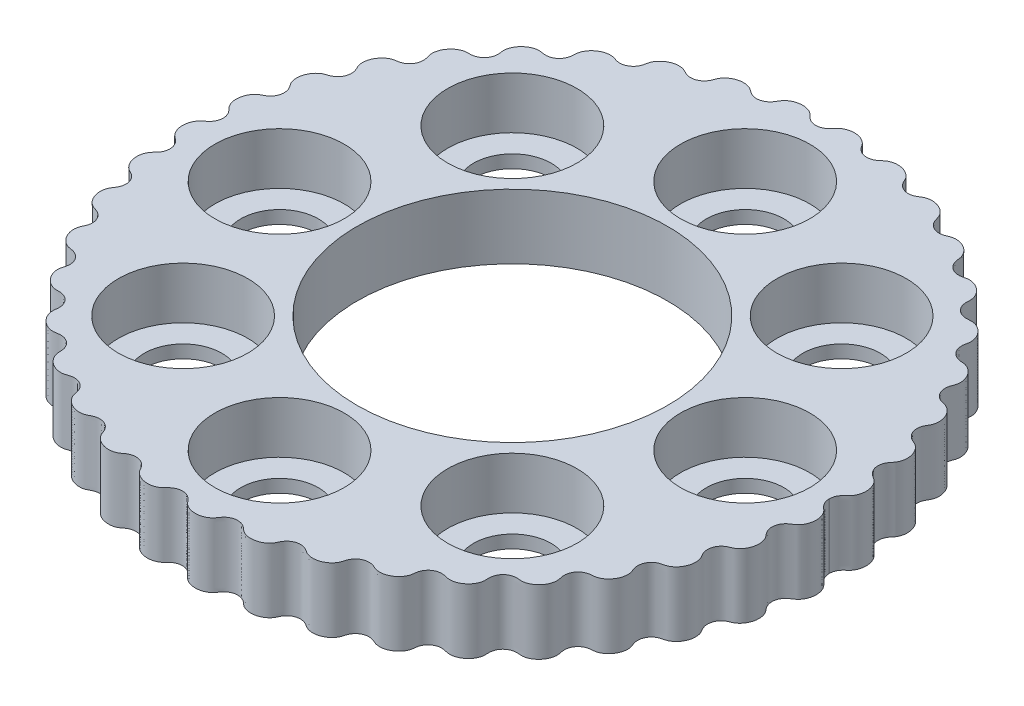
from build123d import *

# Parameters (mm, degrees)
BOSS_EXTRUDE1_DEPTH = 5
SKETCH2_R           = 12
CUT_EXTRUDE1_DEPTH  = 37.39383791
HOLE1_D             = 6
HOLE1_CBORE_D       = 10
HOLE1_CBORE_DEPTH   = 4


with BuildPart() as part:
    # Sketch1 → Boss-Extrude1 (new body)
    with BuildSketch(Plane(origin=(0, 0, 0), x_dir=(1, 0, 0), z_dir=(0, 1, 0))):
        with BuildLine():
            add(Edge.make_bspline(
                [(24.5, 0), (24.5, -0.032701576), (24.503643768, -0.098935065), (24.520100091, -0.231557515), (24.563306695, -0.37104905), (24.630474901, -0.517913129), (24.723536718, -0.659065523), (24.842442784, -0.7928284), (24.987483312, -0.908750967), (25.151066474, -1.063330899), (25.293016736, -1.285136586), (25.404935248, -1.590500326), (25.442358968, -1.973679703), (25.388238682, -2.341450403), (25.249908888, -2.662669139), (25.066237715, -2.92385167), (24.843285187, -3.097823526), (24.551710812, -3.251747242), (24.291807971, -3.54096186), (24.15685552, -3.887170811), (24.159964199, -4.245303416), (24.253524541, -4.539087991), (24.385168231, -4.771968939), (24.638807178, -5.019239878), (24.797525088, -5.397374474), (24.830645532, -5.836257731), (24.734992765, -6.249812375), (24.58195143, -6.558483237), (24.390234299, -6.791981719), (24.184935034, -6.970555692), (23.940854728, -7.065125184), (23.70713488, -7.165908686), (23.508700997, -7.31905902), (23.350412873, -7.502267838), (23.216949128, -7.764654988), (23.163202291, -8.07171217), (23.205655511, -8.393877158), (23.34132919, -8.675141439), (23.491049407, -8.894217402), (23.576162085, -9.177606247), (23.59831681, -9.499805745), (23.534839494, -9.847196253), (23.379813306, -10.190594913), (23.178906945, -10.450991493), (22.967567423, -10.630525296), (22.76488017, -10.742756992), (22.589184766, -10.797744014), (22.386815411, -10.837748424), (22.190086395, -10.90441667), (21.996608796, -11.016922348), (21.765137053, -11.234569902), (21.595631107, -11.53507583), (21.539371156, -11.906162162), (21.632077907, -12.284690713), (21.764581598, -12.549564385), (21.789593453, -12.787020837), (21.782131116, -13.023382407), (21.727181452, -13.289110072), (21.59506174, -13.600213655), (21.343195365, -13.928402366), (21.015174902, -14.168242881), (20.694719635, -14.280355125), (20.431319487, -14.282746618), (20.221891409, -14.310542511), (20.031331573, -14.365707475), (19.783881331, -14.493589444), (19.520218372, -14.750869647), (19.369080078, -15.105193456), (19.358026889, -15.501401935), (19.462600465, -15.83346109), (19.464472547, -16.137599181), (19.37969254, -16.467079723), (19.204137399, -16.797533997), (18.949742977, -17.076011566), (18.638873742, -17.274855126), (18.321682815, -17.389270021), (18.023392039, -17.405995877), (17.688466473, -17.348112955), (17.287573913, -17.422084381), (16.911103922, -17.660362817), (16.700986893, -18.014992072), (16.640562093, -18.330352665), (16.644508053, -18.592116874), (16.666618816, -18.82601978), (16.606844203, -19.103025495), (16.448349531, -19.431276831), (16.176752733, -19.744917149), (15.826597454, -19.975949924), (15.461825511, -20.085392014), (15.163898314, -20.094151912), (14.952002423, -20.049830261), (14.788464306, -20.001991568), (14.620523725, -19.975251306), (14.45147131, -19.973404939), (14.183542584, -20.011245044), (13.906637744, -20.136429959), (13.663310346, -20.365573728), (13.518257574, -20.658305683), (13.463367162, -20.873569048), (13.445828874, -21.065140231), (13.425857061, -21.227322141), (13.366593985, -21.41847997), (13.257220751, -21.627294), (13.067172231, -21.864497221), (12.773861495, -22.093697123), (12.447891767, -22.238196814), (12.113896771, -22.296901293), (11.843875828, -22.283192938), (11.645465808, -22.233946607), (11.478617258, -22.156632084), (11.326566352, -22.091661043), (11.144171978, -22.042843566), (10.93280916, -22.022823141), (10.645185326, -22.057480979), (10.363136796, -22.186462408), (10.140796211, -22.389999892), (9.978092899, -22.655161286), (9.908251546, -22.87392518), (9.860799925, -23.078666197), (9.75249434, -23.294506554), (9.598536155, -23.496595438), (9.355144691, -23.704201974), (9.012124782, -23.875609573), (8.668664808, -23.95138897), (8.351201234, -23.946909882), (8.105808961, -23.889981012), (7.933631196, -23.815733873), (7.793147129, -23.723462446), (7.667924569, -23.641344236), (7.516461261, -23.566205562), (7.337194915, -23.508022206), (7.051498599, -23.471278457), (6.693066572, -23.537697113), (6.365459458, -23.748903989), (6.158387947, -24.048645001), (6.064280146, -24.292320291), (5.942663508, -24.494976469), (5.777090182, -24.672238149), (5.520247205, -24.85479003), (5.157666726, -24.994457926), (4.786540614, -25.037338845), (4.432716206, -24.988008594), (4.169505623, -24.884468622), (3.995068344, -24.76880541), (3.865593686, -24.64527273), (3.75246931, -24.546581843), (3.609348309, -24.448937311), (3.431420351, -24.36469604), (3.162117249, -24.297268542), (2.858943617, -24.313903225), (2.575335551, -24.420915597), (2.355767483, -24.59000056), (2.224626458, -24.736967098), (2.127382836, -24.881995375), (2.043045477, -25.009111373), (1.905164792, -25.158865975), (1.698793095, -25.308147239), (1.397681156, -25.439850125), (1.001127424, -25.502965238), (0.629360335, -25.465313763), (0.307665383, -25.346652272), (0.083554098, -25.19865266), (-0.053247669, -25.060384865), (-0.177849686, -24.892575478), (-0.322474899, -24.735152133), (-0.518785328, -24.595698957), (-0.766051172, -24.499605568), (-1.014597734, -24.467450024), (-1.263114194, -24.492889318), (-1.493381339, -24.576146047), (-1.712279009, -24.70975626), (-1.890397157, -24.901293679), (-2.07636994, -25.098671273), (-2.32866393, -25.22802569), (-2.632218006, -25.321000895), (-2.995349195, -25.34150683), (-3.391344602, -25.269405683), (-3.725708861, -25.099770463), (-3.950250651, -24.900993941), (-4.079020729, -24.714342503), (-4.149949565, -24.578033667), (-4.268658176, -24.384436824), (-4.484903431, -24.155114304), (-4.801886029, -23.992662617), (-5.18889878, -23.961589677), (-5.490584047, -24.041418887), (-5.694287921, -24.146931761), (-5.850720051, -24.266746839), (-5.981065814, -24.369719852), (-6.16040384, -24.467085743), (-6.390667633, -24.539033606), (-6.697487103, -24.571284548), (-7.070614148, -24.521629541), (-7.403348707, -24.388735134), (-7.679033172, -24.191057274), (-7.858081579, -23.988606269), (-7.962893041, -23.812724578), (-8.023941839, -23.638949697), (-8.081282296, -23.483450327), (-8.170475424, -23.317503881), (-8.299773492, -23.150624497), (-8.519647903, -22.965662536), (-8.804465638, -22.847481657), (-9.105365522, -22.822461261), (-9.411188115, -22.884555638), (-9.621120987, -22.983491909), (-9.801541329, -23.093233424), (-10.031431095, -23.167757994), (-10.283339155, -23.19913264), (-10.602501211, -23.170425084), (-10.963787103, -23.044588325), (-11.259514034, -22.852072085), (-11.476293472, -22.621632625), (-11.630063579, -22.374885002), (-11.708363863, -22.123831658), (-11.736343148, -21.861885396), (-11.844524314, -21.61783222), (-12.032186567, -21.35340592), (-12.328822609, -21.137070451), (-12.705385685, -21.04295641), (-13.066996729, -21.097160696), (-13.307409925, -21.196997793), (-13.536665508, -21.252944303), (-13.77837002, -21.258651481), (-14.086089217, -21.203595324), (-14.431964506, -21.045493598), (-14.721938037, -20.816198333), (-14.930817787, -20.535754134), (-15.065261018, -20.246125075), (-15.10442204, -19.966040465), (-15.091955143, -19.636584148), (-15.21243879, -19.266876702), (-15.444788891, -18.976893756), (-15.756476898, -18.800505647), (-16.057689237, -18.734631805), (-16.325183333, -18.732180078), (-16.66614191, -18.828207236), (-17.072976965, -18.776617811), (-17.469630111, -18.585866473), (-17.779960001, -18.296264193), (-17.970766089, -18.009395581), (-18.077132086, -17.726619757), (-18.129143592, -17.459541596), (-18.089017162, -17.200873352), (-18.059424342, -16.948069783), (-18.092832029, -16.699643303), (-18.172342041, -16.470956712), (-18.33282806, -16.224182803), (-18.571854469, -16.024097936), (-18.872076179, -15.89976478), (-19.183499821, -15.876607617), (-19.448092275, -15.896740831), (-19.736076884, -15.828769667), (-20.026191899, -15.686865182), (-20.295309156, -15.458206374), (-20.515197271, -15.152256349), (-20.640263667, -14.848072234), (-20.690084273, -14.575281258), (-20.685945413, -14.343634561), (-20.645728369, -14.163984974), (-20.579189997, -13.968731532), (-20.538550902, -13.765032935), (-20.539232213, -13.541223669), (-20.611966932, -13.231930197), (-20.787450797, -12.934860229), (-21.080687212, -12.700582672), (-21.454854635, -12.591586732), (-21.750490597, -12.573906381), (-21.968640165, -12.476853202), (-22.169606876, -12.352216696), (-22.372265422, -12.171772927), (-22.575637161, -11.901807523), (-22.733936024, -11.519595952), (-22.777646195, -11.115603164), (-22.714525969, -10.782022834), (-22.584907631, -10.55270908), (-22.504249042, -10.357454899), (-22.456753436, -10.164837452), (-22.443729303, -9.886632044), (-22.53474337, -9.529600964), (-22.765917454, -9.221603427), (-23.103644674, -9.013804048), (-23.443302736, -8.938486015), (-23.707993378, -8.787795021), (-23.950263879, -8.550142078), (-24.150007487, -8.231911552), (-24.261724149, -7.874028108), (-24.28186652, -7.502915611), (-24.224809823, -7.211523469), (-24.139392481, -7.004744462), (-24.011104239, -6.822269336), (-23.857646612, -6.606828934), (-23.729838266, -6.261894418), (-23.751281283, -5.814263996), (-23.951133676, -5.456586741), (-24.195158438, -5.245732176), (-24.423265351, -5.118668975), (-24.637193052, -5.020649154), (-24.847031957, -4.830520586), (-25.052168709, -4.529069833), (-25.187932756, -4.137109743), (-25.21300136, -3.718333183), (-25.125395894, -3.347743415), (-24.984061866, -3.085338615), (-24.8397622, -2.923975617), (-24.716507014, -2.806333623), (-24.582959911, -2.641350087), (-24.435425812, -2.363628655), (-24.381922694, -2.017749962), (-24.468738378, -1.65011605), (-24.649609453, -1.378154585), (-24.808636544, -1.222902747), (-24.965741316, -1.111943364), (-25.096247421, -1.013546718), (-25.232180718, -0.866657289), (-25.358361578, -0.667519589), (-25.468779713, -0.384324223), (-25.52063487, -0.015695004), (-25.482799073, 0.33885919), (-25.366652837, 0.657464653), (-25.219778482, 0.884459828), (-25.077933053, 1.031673651), (-24.927554276, 1.137514944), (-24.795258705, 1.236705504), (-24.661779407, 1.370248952), (-24.538753327, 1.543277408), (-24.424946331, 1.809683005), (-24.395606024, 2.118427578), (-24.460685223, 2.412754489), (-24.608956423, 2.686249806), (-24.763487188, 2.856131444), (-24.917080186, 2.999593648), (-25.049860196, 3.201302698), (-25.147903631, 3.435675684), (-25.206010822, 3.750259895), (-25.182955693, 4.13302861), (-25.076862764, 4.468366321), (-24.914260914, 4.741064338), (-24.742269627, 4.925121879), (-24.591886352, 5.037116502), (-24.441737465, 5.112647655), (-24.308008591, 5.180030868), (-24.167201935, 5.273626227), (-24.027175363, 5.399777354), (-23.852494503, 5.628818781), (-23.730781573, 5.972437924), (-23.749874005, 6.361759002), (-23.905908751, 6.690967374), (-24.069879882, 6.894304953), (-24.184586702, 7.100946815), (-24.255321137, 7.332965409), (-24.285005422, 7.646671642), (-24.224682662, 8.030512168), (-24.076266111, 8.373361154), (-23.856641931, 8.655124788), (-23.635374032, 8.831310188), (-23.4479903, 8.924556929), (-23.276267219, 8.974922807), (-23.134229945, 9.023544143), (-22.978107304, 9.098662598), (-22.816193856, 9.210620378), (-22.623144868, 9.410113172), (-22.485950659, 9.680969632), (-22.436801923, 9.980084626), (-22.473435619, 10.254787868), (-22.535133786, 10.441849655), (-22.612107, 10.598584042), (-22.68002941, 10.735179433), (-22.740790781, 10.92946286), (-22.766895917, 11.182826715), (-22.730409086, 11.509450177), (-22.586802924, 11.884437908), (-22.368321683, 12.187578437), (-22.104717627, 12.406852922), (-21.864496168, 12.526947954), (-21.676356137, 12.576297871), (-21.468731485, 12.600303424), (-21.260084052, 12.646829229), (-21.041148953, 12.747104702), (-20.834288709, 12.91318749), (-20.682161616, 13.112348775), (-20.579924676, 13.340281597), (-20.536879444, 13.581322021), (-20.543127831, 13.837701107), (-20.61993552, 14.087734481), (-20.697897488, 14.347478781), (-20.683785544, 14.630648111), (-20.612539798, 14.940016064), (-20.448751, 15.264743617), (-20.188340372, 15.571630931), (-19.874283356, 15.776390385), (-19.58989404, 15.871482442), (-19.363878668, 15.889707198), (-19.210373958, 15.882982764), (-18.983382566, 15.888963171), (-18.676671333, 15.96152067), (-18.377464779, 16.154744755), (-18.156980749, 16.474328488), (-18.075213086, 16.775518432), (-18.064704915, 17.004712456), (-18.090236138, 17.200114585), (-18.114255608, 17.36449287), (-18.108933176, 17.568502975), (-18.05612259, 17.803915635), (-17.930651687, 18.085776991), (-17.701086983, 18.384107508), (-17.419631567, 18.605829308), (-17.110599699, 18.745750942), (-16.845749829, 18.799595156), (-16.641024702, 18.802435031), (-16.4600043, 18.768421661), (-16.296666195, 18.740325413), (-16.108358519, 18.734588876), (-15.899193762, 18.763114982), (-15.629078352, 18.861033231), (-15.384315321, 19.048581969), (-15.212178088, 19.296648508), (-15.113024415, 19.592546119), (-15.093725111, 19.823828708), (-15.098560094, 20.034951984), (-15.048167216, 20.271307357), (-14.949392422, 20.505157651), (-14.764959019, 20.767212125), (-14.475345402, 21.01718574), (-14.160763397, 21.17704356), (-13.852808891, 21.249571547), (-13.562235167, 21.259376051), (-13.305661875, 21.201675545), (-13.06482084, 21.094926302), (-12.799373568, 21.066575419), (-12.476542263, 21.096870033), (-12.140863779, 21.245583359), (-11.871067, 21.524628417), (-11.737189182, 21.864887905), (-11.703439736, 22.123010606), (-11.637276199, 22.349525559), (-11.521374322, 22.561705269), (-11.31984408, 22.800676005), (-11.009992109, 23.021172204), (-10.666434991, 23.157658443), (-10.319123465, 23.198344101), (-10.001074181, 23.169970457), (-9.738921246, 23.06385684), (-9.459849139, 22.888328263), (-9.079427677, 22.807797091), (-8.712117326, 22.864012348), (-8.403512033, 23.045732007), (-8.195848453, 23.273651867), (-8.059966313, 23.504068211), (-7.972655419, 23.847358396), (-7.724579848, 24.173907814), (-7.36105968, 24.422054462), (-6.955099038, 24.546020126), (-6.611259468, 24.567839392), (-6.313185531, 24.518577658), (-6.055880329, 24.43009339), (-5.851919935, 24.266019174), (-5.647785122, 24.11397488), (-5.415939164, 24.018685848), (-5.178139922, 23.973191764), (-4.884194769, 23.988777218), (-4.591403955, 24.095715763), (-4.333607356, 24.2935338), (-4.157819496, 24.55164922), (-4.042964029, 24.79087051), (-3.840115515, 25.006299157), (-3.572170309, 25.186602314), (-3.239592042, 25.305345982), (-2.864687997, 25.342810633), (-2.538722493, 25.299039593), (-2.277564653, 25.205798931), (-2.079018791, 25.08639998), (-1.943541483, 24.961755602), (-1.807720479, 24.806509118), (-1.651644155, 24.669459743), (-1.457485385, 24.558134218), (-1.153262859, 24.466457612), (-0.808237443, 24.469878116), (-0.458720598, 24.606680292), (-0.177228594, 24.876210672), (-0.014104915, 25.123398405), (0.179008415, 25.263802283), (0.387425394, 25.375532034), (0.645020401, 25.460827317), (0.980501642, 25.501978977), (1.390658771, 25.447977983), (1.762384823, 25.283846397), (2.019725823, 25.062406114), (2.15351457, 24.835500228), (2.282270706, 24.668017861), (2.425322993, 24.530573791), (2.659730685, 24.380184215), (3.01442567, 24.280462003), (3.396760716, 24.326646912), (3.74559112, 24.515207009), (3.98067506, 24.771710168), (4.243474716, 24.925598931), (4.570491374, 25.016613388), (4.945822077, 25.030456195), (5.311853071, 24.948340654), (5.642960757, 24.780135835), (5.867321298, 24.585186526), (6.002816037, 24.40757651), (6.082617526, 24.239649681), (6.143014812, 24.102783436), (6.256496421, 23.906200771), (6.475873367, 23.663671191), (6.84074578, 23.476485108), (7.249746685, 23.470510833), (7.554708121, 23.576499668), (7.778642915, 23.710460716), (7.970578753, 23.846748431), (8.240096269, 23.933407518), (8.60375155, 23.960355436), (9.011048548, 23.881963227), (9.386262262, 23.694314342), (9.663394648, 23.433179742), (9.819999487, 23.179604616), (9.887615085, 22.97397282), (9.927858617, 22.808421005), (10.00393204, 22.610288677), (10.170623215, 22.343654899), (10.443360125, 22.124335405), (10.805135853, 22.015628981), (11.131121471, 22.036235558), (11.345120651, 22.096308987), (11.519785829, 22.176883058), (11.670254108, 22.240725393), (11.865438914, 22.285027556), (12.101006134, 22.294752583), (12.401488215, 22.248793509), (12.746677044, 22.109393741), (13.034823546, 21.899354845), (13.252680159, 21.639473782), (13.375834746, 21.398784096), (13.432414447, 21.202337972), (13.448890401, 21.019185397), (13.468638938, 20.85501761), (13.517543727, 20.67264816), (13.60586848, 20.479588065), (13.779663044, 20.247823607), (14.032358547, 20.06803061), (14.319787987, 19.977208032), (14.630778813, 19.968850467), (14.855177442, 20.017726403), (15.056217534, 20.079018872), (15.297291844, 20.093166757), (15.549287998, 20.060897239), (15.850782761, 19.953937558), (16.170749204, 19.742596345), (16.408121357, 19.483055655), (16.562993544, 19.205894035), (16.63640498, 18.964919226), (16.658213109, 18.778687018), (16.648555386, 18.610888846), (16.640042837, 18.46138545), (16.650688447, 18.292646212), (16.689917132, 18.108302827), (16.800920524, 17.842497429), (17.037637151, 17.565267227), (17.384339384, 17.387127859), (17.747460659, 17.357638276), (18.005539927, 17.397969126), (18.241847235, 17.394000312), (18.478149881, 17.33925722), (18.764673246, 17.20812228), (19.066935592, 16.963969627), (19.289651883, 16.664019815), (19.423865678, 16.332941995), (19.465822798, 16.053226388), (19.452895799, 15.844320221), (19.410654089, 15.670415923), (19.381738066, 15.523092826), (19.368726553, 15.350330722), (19.384720773, 15.154141381), (19.460945821, 14.887215032), (19.626895887, 14.632969919), (19.861350058, 14.440832499), (20.117567804, 14.335189625), (20.310419234, 14.295080554), (20.484644338, 14.28336863), (20.636902679, 14.273899702), (20.835540843, 14.229386133), (21.068018552, 14.125326032), (21.332644766, 13.930413542), (21.585602598, 13.618579731), (21.738896034, 13.277774003), (21.797008441, 12.939895421), (21.780905827, 12.67174863), (21.72959702, 12.484236563), (21.646551068, 12.292214426), (21.58256809, 12.088742724), (21.559818546, 11.848093822), (21.609856376, 11.526335568), (21.752983103, 11.242122588), (21.975402422, 11.023555203), (22.255379338, 10.872576217), (22.51021401, 10.813187021), (22.774210944, 10.751372295), (23.012355677, 10.597286148), (23.244677282, 10.381095353), (23.443992345, 10.076771401), (23.579581757, 9.697928801), (23.599897219, 9.323530725), (23.540090595, 9.029739909), (23.442899473, 8.824874226), (23.360330858, 8.695306852), (23.252003307, 8.495767511), (23.161441631, 8.19390654), (23.179105474, 7.838181556), (23.345559542, 7.487408483), (23.565492426, 7.2659443), (23.758729327, 7.142207457), (23.940730991, 7.066590855), (24.095107348, 7.005215414), (24.269158958, 6.898608067), (24.446637726, 6.735178668), (24.62870107, 6.484671358), (24.772762891, 6.134520477), (24.823520919, 5.777352144), (24.788138797, 5.437644156), (24.700089209, 5.179912993), (24.597259421, 5.001117625), (24.474854125, 4.860415749), (24.368107939, 4.729862168), (24.270037493, 4.565584266), (24.192790878, 4.36600647), (24.148702851, 4.080575962), (24.195587285, 3.776774954), (24.328328535, 3.511121641), (24.537077517, 3.280103731), (24.731113722, 3.151313906), (24.920460396, 3.044948594), (25.0679466, 2.903334114), (25.1719778, 2.772634595), (25.281922527, 2.588557051), (25.384681035, 2.327359304), (25.442050959, 1.989113878), (25.412737048, 1.624513222), (25.302488261, 1.302409632), (25.155369227, 1.068828132), (25.003788737, 0.924898681), (24.861104404, 0.803305369), (24.749137308, 0.699511204), (24.641312064, 0.52759851), (24.550490368, 0.376428536), (24.510248462, 0.164569644), (24.500037563, 0.05522408), (24.500000245, 0.000716469)],
                knots=[0.067666644, 0.067666644, 0.067666644, 0.067666644, 0.067666644, 0.068384525, 0.069102406, 0.069820287, 0.070538168, 0.071421007, 0.072303847, 0.073186687, 0.074069526, 0.075663586, 0.077257645, 0.079287793, 0.08131794, 0.082593638, 0.083869336, 0.085257156, 0.086644976, 0.088818664, 0.091044217, 0.092148055, 0.093251893, 0.094655618, 0.096059344, 0.098783864, 0.100818131, 0.102852398, 0.104037285, 0.105222172, 0.106566772, 0.107911371, 0.108976353, 0.110041335, 0.11126547, 0.112489605, 0.114477485, 0.115880621, 0.117283757, 0.118381293, 0.11947883, 0.121425739, 0.123372649, 0.124975842, 0.126579035, 0.127594759, 0.128610483, 0.129335069, 0.130059656, 0.13150883, 0.132526666, 0.133544502, 0.136038431, 0.137927708, 0.139389661, 0.140851614, 0.141612703, 0.142373791, 0.143895968, 0.145942594, 0.147989221, 0.150092297, 0.151522402, 0.152237455, 0.152952507, 0.154103779, 0.15525505, 0.157496311, 0.15977388, 0.161189651, 0.162605422, 0.164039653, 0.165473884, 0.16756908, 0.169664276, 0.171056797, 0.172449319, 0.17386821, 0.175287102, 0.177453396, 0.179996183, 0.182056602, 0.18277897, 0.183501337, 0.184946073, 0.186499114, 0.188052156, 0.190377238, 0.19270232, 0.194342788, 0.195163022, 0.195983256, 0.196781535, 0.197579815, 0.198378095, 0.199176375, 0.201896006, 0.203215219, 0.204534433, 0.205309298, 0.206084162, 0.206859027, 0.207633891, 0.209083646, 0.210533401, 0.212580076, 0.214626752, 0.215764154, 0.216901555, 0.217684808, 0.218468061, 0.219251313, 0.220034566, 0.221252749, 0.222470932, 0.224697751, 0.225787335, 0.22687692, 0.228317271, 0.229037447, 0.229757623, 0.231433215, 0.233108807, 0.235037779, 0.236966751, 0.23802442, 0.23908209, 0.239791888, 0.240501687, 0.241211485, 0.241921284, 0.242990513, 0.244059742, 0.24664089, 0.248666879, 0.250124635, 0.250853513, 0.251582391, 0.253135161, 0.254687931, 0.25678004, 0.258872149, 0.260132575, 0.261393, 0.262103899, 0.262814797, 0.263525695, 0.264236593, 0.265383261, 0.26652993, 0.268746926, 0.269884368, 0.271021811, 0.271745191, 0.272468571, 0.273191951, 0.273915331, 0.275590025, 0.277264719, 0.279359367, 0.281454014, 0.282580004, 0.283705995, 0.284415514, 0.285125033, 0.286544071, 0.287741584, 0.288939097, 0.290102412, 0.291265726, 0.292418015, 0.293570304, 0.294896123, 0.296221941, 0.297533289, 0.298844637, 0.300928647, 0.303012657, 0.305102586, 0.30583198, 0.306561373, 0.307290766, 0.308020159, 0.310134642, 0.312461837, 0.313832341, 0.315202845, 0.31599054, 0.316778235, 0.317565931, 0.318353626, 0.319839929, 0.321326232, 0.323372892, 0.325419552, 0.326556766, 0.32769398, 0.328479126, 0.329264273, 0.33004942, 0.330834566, 0.332039904, 0.333245242, 0.335450599, 0.336560183, 0.337669767, 0.339110813, 0.339831336, 0.340551859, 0.342227219, 0.343902578, 0.345831443, 0.347760307, 0.348818958, 0.349877608, 0.351296011, 0.352714413, 0.353786522, 0.35485863, 0.357437011, 0.359473842, 0.360924648, 0.361650051, 0.362375454, 0.363928416, 0.365481378, 0.367511525, 0.369541673, 0.370817371, 0.372093068, 0.373480933, 0.374868797, 0.377042236, 0.37926811, 0.38037185, 0.38147559, 0.382879333, 0.384283076, 0.387007593, 0.38904186, 0.391076127, 0.392261014, 0.393445901, 0.394790487, 0.396135074, 0.397200124, 0.398265175, 0.399489214, 0.400713253, 0.402701078, 0.40410429, 0.405507501, 0.406605033, 0.407702564, 0.409649474, 0.411596384, 0.413199578, 0.414802771, 0.415818497, 0.416834223, 0.417558779, 0.418283336, 0.419732448, 0.420750322, 0.421768195, 0.424262225, 0.426151521, 0.427613432, 0.429075344, 0.429836433, 0.430597522, 0.4321197, 0.434166326, 0.436212953, 0.438316027, 0.439746131, 0.440461183, 0.441176235, 0.442327449, 0.443478664, 0.445719896, 0.447997631, 0.449413395, 0.450829159, 0.452263387, 0.453697616, 0.455792812, 0.457888007, 0.459280531, 0.460673054, 0.461382502, 0.462091951, 0.463510847, 0.465677255, 0.468219851, 0.470280377, 0.471002734, 0.471725092, 0.473169806, 0.474722848, 0.47627589, 0.478600837, 0.480925784, 0.482566215, 0.483386431, 0.484206647, 0.485004816, 0.485802985, 0.487399324, 0.490118928, 0.491438332, 0.492757736, 0.493532641, 0.494307547, 0.495082453, 0.495857358, 0.497307245, 0.498757133, 0.500803808, 0.502850483, 0.503987885, 0.505125286, 0.505908541, 0.506691797, 0.507475052, 0.508258308, 0.509476471, 0.510694635, 0.512921334, 0.514010995, 0.515100657, 0.516541008, 0.517261184, 0.51798136, 0.519656951, 0.521332543, 0.523261514, 0.525190486, 0.52624816, 0.527305833, 0.528015628, 0.528725423, 0.529435218, 0.530145012, 0.531214238, 0.532283465, 0.534864663, 0.536890665, 0.538348394, 0.539077258, 0.539806123, 0.541358894, 0.542911665, 0.545003774, 0.547095883, 0.548356309, 0.549616735, 0.550327659, 0.551038583, 0.551749507, 0.552460431, 0.553606967, 0.554753504, 0.55697057, 0.558108041, 0.559245512, 0.559968901, 0.560692289, 0.561415678, 0.562139066, 0.563813758, 0.565488451, 0.567583099, 0.569677747, 0.570803738, 0.57192973, 0.572639232, 0.573348733, 0.574767736, 0.575965326, 0.577162916, 0.578326123, 0.579489331, 0.580641702, 0.581794073, 0.583119874, 0.584445674, 0.585757024, 0.587068373, 0.589152252, 0.591236132, 0.593325935, 0.594055294, 0.594784654, 0.595514013, 0.596243372, 0.598357525, 0.600684721, 0.602055409, 0.603426096, 0.604213844, 0.605001593, 0.605789341, 0.606577089, 0.608063526, 0.609549963, 0.611596624, 0.613643284, 0.614780497, 0.61591771, 0.616702867, 0.617488025, 0.618273182, 0.61905834, 0.6202636, 0.62146886, 0.623674189, 0.624783841, 0.625893493, 0.627334544, 0.62805507, 0.628775595, 0.630450954, 0.632126312, 0.634055176, 0.635984041, 0.637042694, 0.638101348, 0.639519749, 0.64093815, 0.642010283, 0.643082416, 0.645660727, 0.647697623, 0.649148405, 0.649873796, 0.650599187, 0.652152149, 0.653705112, 0.655735259, 0.657765407, 0.659041104, 0.660316802, 0.66170471, 0.663092619, 0.66526581, 0.667492005, 0.668595646, 0.669699287, 0.671103049, 0.67250681, 0.675231323, 0.67726559, 0.679299857, 0.680484744, 0.681669632, 0.683014205, 0.684358778, 0.685423897, 0.686489016, 0.687712959, 0.688936902, 0.690924673, 0.69232796, 0.693731246, 0.694828773, 0.6959263, 0.69787321, 0.699820121, 0.701423314, 0.703026508, 0.704042236, 0.705057965, 0.705782491, 0.706507016, 0.707956068, 0.708973979, 0.70999189, 0.712486021, 0.714375334, 0.715837205, 0.717299075, 0.718060165, 0.718821254, 0.720343433, 0.722390059, 0.724436686, 0.726539757, 0.727969861, 0.728684912, 0.729399964, 0.730551121, 0.731702279, 0.733943484, 0.736221383, 0.73763714, 0.739052897, 0.740487123, 0.741921349, 0.744016545, 0.746111741, 0.747504266, 0.748896791, 0.749606241, 0.750315692, 0.751025143, 0.751734594, 0.753901116, 0.75644352, 0.758504153, 0.7592265, 0.759948847, 0.761393542, 0.762946583, 0.764499625, 0.766824437, 0.769149249, 0.770789644, 0.771609842, 0.772430039, 0.773228098, 0.774026157, 0.775622274, 0.778341852, 0.779661446, 0.780981039, 0.781755986, 0.782530933, 0.78330588, 0.784080826, 0.785530846, 0.786980865, 0.789027541, 0.791074216, 0.792211617, 0.793349017, 0.794132276, 0.794915534, 0.795698793, 0.796482051, 0.797700195, 0.798918338, 0.801144918, 0.802234657, 0.803324395, 0.804764747, 0.805484923, 0.806205099, 0.807880689, 0.80955628, 0.811485251, 0.813414222, 0.8144719, 0.815529578, 0.816239369, 0.81694916, 0.817658951, 0.818368742, 0.819437966, 0.820507189, 0.823088436, 0.825114451, 0.826572154, 0.827301005, 0.828029856, 0.829582628, 0.8311354, 0.833227509, 0.835319618, 0.836580044, 0.83784047, 0.83855142, 0.83926237, 0.83997332, 0.84068427, 0.841830675, 0.84297708, 0.845194216, 0.846331715, 0.847469215, 0.848192612, 0.848916009, 0.849639405, 0.850362802, 0.852037492, 0.853712183, 0.855806832, 0.85790148, 0.859027474, 0.860153467, 0.860862951, 0.861572435, 0.862991402, 0.864189069, 0.865386736, 0.867712936, 0.86886539, 0.870017844, 0.871343626, 0.872669408, 0.873980759, 0.87529211, 0.877375859, 0.879459607, 0.881549284, 0.88227861, 0.883007935, 0.883737261, 0.884466587, 0.886580408, 0.888907606, 0.890278477, 0.891649349, 0.89243715, 0.893224951, 0.894012752, 0.894800553, 0.896287125, 0.897773696, 0.899840974, 0.901908251, 0.903046745, 0.904185238, 0.904984226, 0.905783214, 0.906582202, 0.90738119, 0.908598845, 0.909816501, 0.912014313, 0.913081271, 0.914148228, 0.915662834, 0.916420137, 0.91717744, 0.918002263, 0.918827085, 0.920476729, 0.922465691, 0.924454653, 0.925668811, 0.926882968, 0.927646963, 0.928410957, 0.929174952, 0.929938946, 0.931135524, 0.932332102, 0.932332102, 0.932332102, 0.932332102, 0.932332102], degree=4))
            Line((24.5, 0), (24.500000245, 0.000716467))
        make_face()
    extrude(amount=BOSS_EXTRUDE1_DEPTH)

    # Sketch2 → Cut-Extrude1 (cut, through all)
    with BuildSketch(Plane(origin=(0, 5, 0), x_dir=(1, 0, 0), z_dir=(0, 1, 0))):
        with Locations(Location((0, 0, 0), (0, 0, 270))):
            Circle(SKETCH2_R)
    extrude(amount=-CUT_EXTRUDE1_DEPTH, mode=Mode.SUBTRACT)

    # Hole1 (through all)
    with Locations(Plane(origin=(0, 5, 0), x_dir=(1, 0, 0), z_dir=(0, 1, 0))):
        with Locations((18, 0), (12.727922061, -12.727922061), (0, -18), (-12.727922061, -12.727922061), (-18, 0), (-12.727922061, 12.727922061), (0, 18), (12.727922061, 12.727922061)):
            CounterBoreHole(HOLE1_D / 2, HOLE1_CBORE_D / 2, HOLE1_CBORE_DEPTH)


solid = part.part
